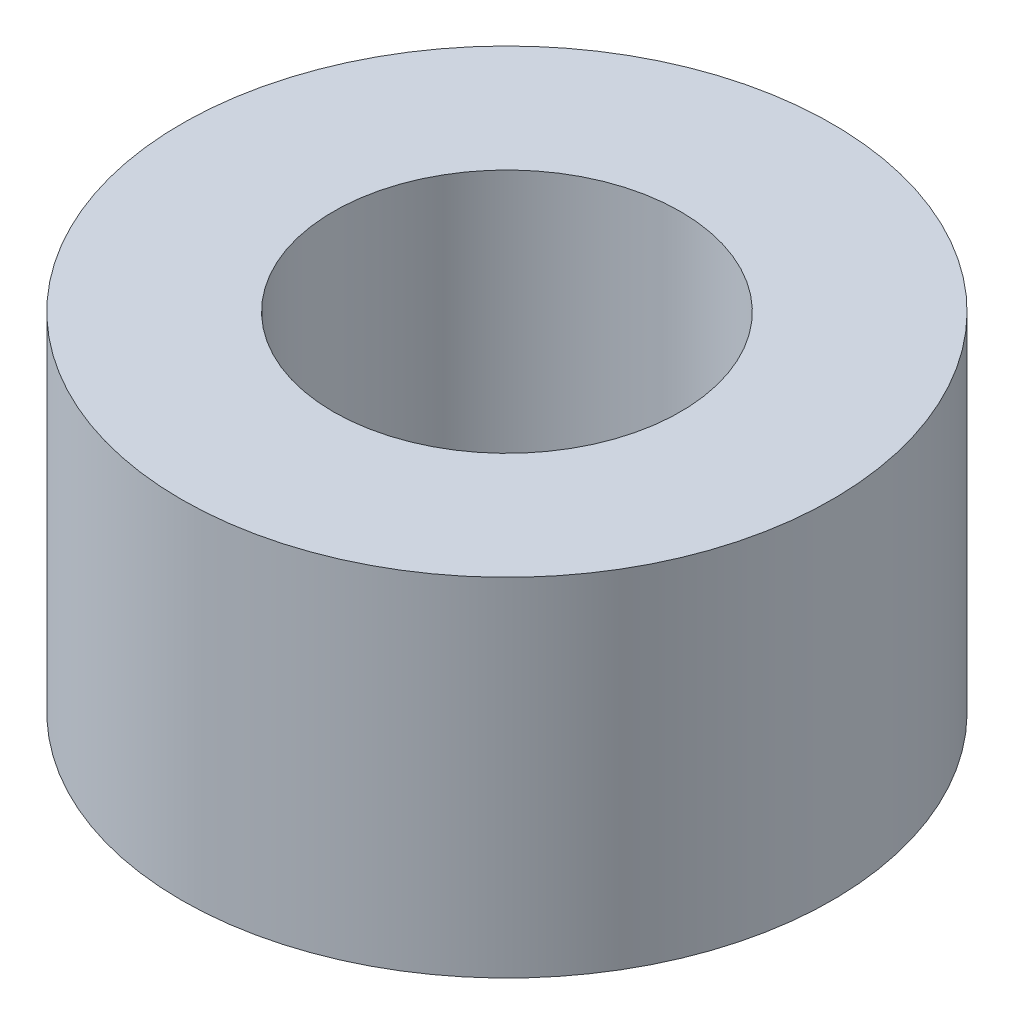
from build123d import *

# Parameters (mm, degrees)
SKETCH1_R           = 7.5
BOSS_EXTRUDE1_DEPTH = 8
SKETCH2_R           = 4
CUT_EXTRUDE1_DEPTH  = 6
SKETCH3_R           = 1.075
CUT_EXTRUDE2_DEPTH  = 6


with BuildPart() as part:
    # Sketch1 → Boss-Extrude1 (new body)
    with BuildSketch(Plane(origin=(0, 0, 0), x_dir=(1, 0, 0), z_dir=(0, 1, 0))):
        with Locations(Location((0, 0, 0), (0, 0, 270))):  # turned: the seam where the file's is
            Circle(SKETCH1_R)
    extrude(amount=BOSS_EXTRUDE1_DEPTH)

    # Sketch2 → Cut-Extrude1 (cut)
    with BuildSketch(Plane(origin=(0, 8, 0), x_dir=(1, 0, 0), z_dir=(0, 1, 0))):
        with Locations(Location((0, 0, 0), (0, 0, 270))):  # turned: the seam where the file's is
            Circle(SKETCH2_R)
    extrude(amount=-CUT_EXTRUDE1_DEPTH, mode=Mode.SUBTRACT)

    # Sketch3 → Cut-Extrude2 (cut)
    with BuildSketch(Plane.XZ):
        with Locations(Location((0, 0, 0), (0, 0, 270))):  # turned: the seam where the file's is
            Circle(SKETCH3_R)
    extrude(amount=-CUT_EXTRUDE2_DEPTH, mode=Mode.SUBTRACT)


solid = part.part
